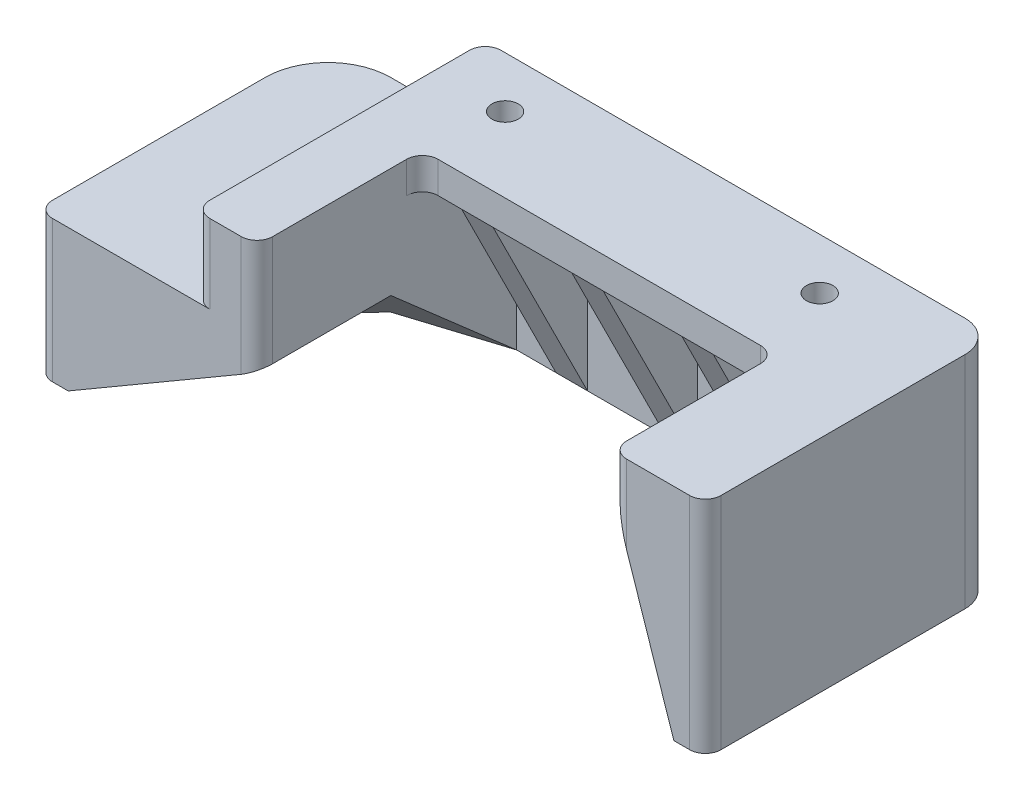
from build123d import *

# Parameters (mm, degrees)
SKETCH2_R           = 2.667
BOSS_EXTRUDE1_DEPTH = 6.35
BOSS_EXTRUDE2_DEPTH = 38.1
CUT_EXTRUDE1_DEPTH  = 50.8
CUT_EXTRUDE2_DEPTH  = 38.1
BOSS_EXTRUDE3_DEPTH = 9.525
BOSS_EXTRUDE4_DEPTH = 6.35
BOSS_EXTRUDE5_DEPTH = 22.225
CUT_EXTRUDE4_DEPTH  = 19.05
CUT_EXTRUDE7_DEPTH  = 19.05
CUT_EXTRUDE8_DEPTH  = 6.35
CUT_EXTRUDE9_DEPTH  = 6.35


with BuildPart() as part:
    # Sketch2 → Boss-Extrude1 (new body)
    with BuildSketch(Plane(origin=(0, 0, 0), x_dir=(1, 0, 0), z_dir=(0, 1, 0))):
        with BuildLine():
            Line((-109.5375, -9.525), (-109.5375, -61.948583794))
            ThreePointArc((-109.5375, -61.948583794), (-108.60756403, -64.193647824), (-106.3625, -65.123583794))
            Line((-106.3625, -65.123583794), (-100.0125, -65.123583794))
            ThreePointArc((-100.0125, -65.123583794), (-97.76743597, -64.193647824), (-96.8375, -61.948583794))
            Line((-96.8375, -61.948583794), (-96.8375, -34.925))
            ThreePointArc((-96.8375, -34.925), (-95.90756403, -32.67993597), (-93.6625, -31.75))
            Line((-93.6625, -31.75), (-28.575, -31.75))
            ThreePointArc((-28.575, -31.75), (-26.32993597, -32.67993597), (-25.4, -34.925))
            Line((-25.4, -34.925), (-25.4, -61.948583794))
            ThreePointArc((-25.4, -61.948583794), (-24.47006403, -64.193647824), (-22.225, -65.123583794))
            Line((-22.225, -65.123583794), (-9.525, -65.123583794))
            ThreePointArc((-9.525, -65.123583794), (-7.27993597, -64.193647824), (-6.35, -61.948583794))
            Line((-6.35, -61.948583794), (-6.35, -12.7))
            ThreePointArc((-6.35, -12.7), (-8.209871939, -8.209871939), (-12.7, -6.35))
            Line((-12.7, -6.35), (-106.3625, -6.35))
            ThreePointArc((-106.3625, -6.35), (-108.60756403, -7.27993597), (-109.5375, -9.525))
        make_face()
        with Locations((-95.25, -16.637060646)):
            Circle(SKETCH2_R, mode=Mode.SUBTRACT)
        with Locations((-31.75, -16.637060646)):
            Circle(SKETCH2_R, mode=Mode.SUBTRACT)
    extrude(amount=-BOSS_EXTRUDE1_DEPTH)

    # Sketch3 → Boss-Extrude2 (add)
    with BuildSketch(Plane.XZ.offset(6.35)):
        with BuildLine():
            Line((-6.35, 61.948583794), (-6.35, 12.7))
            ThreePointArc((-6.35, 12.7), (-8.209871939, 8.209871939), (-12.7, 6.35))
            Line((-12.7, 6.35), (-96.8375, 6.35))
            Line((-96.8375, 6.35), (-96.8375, 12.7))
            Line((-96.8375, 12.7), (-88.9, 12.7))
            Line((-88.9, 12.7), (-88.9, 31.75))
            Line((-88.9, 31.75), (-82.55, 31.75))
            Line((-82.55, 31.75), (-82.55, 12.7))
            Line((-82.55, 12.7), (-66.675, 12.7))
            Line((-66.675, 12.7), (-66.675, 31.75))
            Line((-66.675, 31.75), (-60.325, 31.75))
            Line((-60.325, 31.75), (-60.325, 12.7))
            Line((-60.325, 12.7), (-44.45, 12.7))
            Line((-44.45, 12.7), (-44.45, 31.75))
            Line((-44.45, 31.75), (-38.1, 31.75))
            Line((-38.1, 31.75), (-38.1, 12.7))
            Line((-38.1, 12.7), (-15.875, 12.7))
            ThreePointArc((-15.875, 12.7), (-13.62993597, 13.62993597), (-12.7, 15.875))
            Line((-12.7, 15.875), (-12.7, 27.023583794))
            Line((-12.7, 27.023583794), (-25.4, 27.023583794))
            Line((-25.4, 27.023583794), (-25.4, 33.373583794))
            Line((-25.4, 33.373583794), (-12.7, 33.373583794))
            Line((-12.7, 33.373583794), (-12.7, 42.898583794))
            Line((-12.7, 42.898583794), (-25.4, 42.898583794))
            Line((-25.4, 42.898583794), (-25.4, 49.248583794))
            Line((-25.4, 49.248583794), (-12.7, 49.248583794))
            Line((-12.7, 49.248583794), (-12.7, 58.773583794))
            Line((-12.7, 58.773583794), (-25.4, 58.773583794))
            Line((-25.4, 58.773583794), (-25.4, 61.948583794))
            ThreePointArc((-25.4, 61.948583794), (-24.47006403, 64.193647824), (-22.225, 65.123583794))
            Line((-22.225, 65.123583794), (-9.525, 65.123583794))
            ThreePointArc((-9.525, 65.123583794), (-7.27993597, 64.193647824), (-6.35, 61.948583794))
        make_face()
    extrude(amount=BOSS_EXTRUDE2_DEPTH)

    # Sketch4 → Cut-Extrude1 (cut)
    with BuildSketch(Plane.ZY.offset(88.9)):
        Polygon((31.75, -6.35), (12.7, -44.45), (31.75, -44.45), align=None)
    extrude(amount=-CUT_EXTRUDE1_DEPTH, mode=Mode.SUBTRACT)

    # Sketch5 → Cut-Extrude2 (cut)
    with BuildSketch(Plane.XY.offset(65.123583794)):
        Polygon((-25.4, -6.35), (-12.7, -44.45), (-25.4, -44.45), align=None)
    extrude(amount=-CUT_EXTRUDE2_DEPTH, mode=Mode.SUBTRACT)

    # Sketch6 → Boss-Extrude3 (add)
    with BuildSketch(Plane.XZ.offset(6.35)):
        with BuildLine():
            Line((-96.8375, 6.35), (-106.3625, 6.35))
            ThreePointArc((-106.3625, 6.35), (-108.60756403, 7.27993597), (-109.5375, 9.525))
            Line((-109.5375, 9.525), (-109.5375, 61.948583794))
            ThreePointArc((-109.5375, 61.948583794), (-108.60756403, 64.193647824), (-106.3625, 65.123583794))
            Line((-106.3625, 65.123583794), (-100.0125, 65.123583794))
            ThreePointArc((-100.0125, 65.123583794), (-97.76743597, 64.193647824), (-96.8375, 61.948583794))
            Line((-96.8375, 61.948583794), (-96.8375, 6.35))
        make_face()
    extrude(amount=BOSS_EXTRUDE3_DEPTH)

    # Sketch7 → Boss-Extrude4 (add)
    with BuildSketch(Plane.XZ.offset(15.875)):
        with BuildLine():
            Line((-100.0125, 65.123583794), (-138.1125, 65.123583794))
            ThreePointArc((-138.1125, 65.123583794), (-140.35756403, 64.193647824), (-141.2875, 61.948583794))
            Line((-141.2875, 61.948583794), (-141.2875, 19.05))
            ThreePointArc((-141.2875, 19.05), (-137.567756121, 10.069743879), (-128.5875, 6.35))
            Line((-128.5875, 6.35), (-96.8375, 6.35))
            Line((-96.8375, 6.35), (-96.8375, 61.948583794))
            ThreePointArc((-96.8375, 61.948583794), (-97.76743597, 64.193647824), (-100.0125, 65.123583794))
        make_face()
    extrude(amount=BOSS_EXTRUDE4_DEPTH)

    # Sketch8 → Boss-Extrude5 (add)
    with BuildSketch(Plane.XZ.offset(22.225)):
        with BuildLine():
            Line((-128.5875, 6.35), (-96.8375, 6.35))
            Line((-96.8375, 6.35), (-96.8375, 12.7))
            Line((-96.8375, 12.7), (-96.8375, 38.1))
            Line((-96.8375, 38.1), (-134.9375, 38.1))
            Line((-134.9375, 38.1), (-134.9375, 46.073583794))
            Line((-134.9375, 46.073583794), (-96.8375, 46.073583794))
            Line((-96.8375, 46.073583794), (-96.8375, 52.423583794))
            Line((-96.8375, 52.423583794), (-134.9375, 52.423583794))
            Line((-134.9375, 52.423583794), (-134.9375, 58.773583794))
            Line((-134.9375, 58.773583794), (-96.8375, 58.773583794))
            Line((-96.8375, 58.773583794), (-96.8375, 61.948583794))
            ThreePointArc((-96.8375, 61.948583794), (-97.76743597, 64.193647824), (-100.0125, 65.123583794))
            Line((-100.0125, 65.123583794), (-138.1125, 65.123583794))
            ThreePointArc((-138.1125, 65.123583794), (-140.35756403, 64.193647824), (-141.2875, 61.948583794))
            Line((-141.2875, 61.948583794), (-141.2875, 19.05))
            ThreePointArc((-141.2875, 19.05), (-137.567756121, 10.069743879), (-128.5875, 6.35))
        make_face()
        with BuildLine():
            Line((-128.5875, 12.7), (-103.1875, 12.7))
            Line((-103.1875, 12.7), (-103.1875, 31.75))
            Line((-103.1875, 31.75), (-134.9375, 31.75))
            Line((-134.9375, 31.75), (-134.9375, 19.05))
            ThreePointArc((-134.9375, 19.05), (-133.07762806, 14.559871939), (-128.5875, 12.7))
        make_face(mode=Mode.SUBTRACT)
    extrude(amount=BOSS_EXTRUDE5_DEPTH)

    # Sketch11 → Cut-Extrude4 (cut)
    with BuildSketch(Plane.XY.offset(65.123583794)):
        Polygon((-134.9375, -44.45), (-96.8375, -22.225), (-96.8375, -44.45), align=None)
    extrude(amount=-CUT_EXTRUDE4_DEPTH, mode=Mode.SUBTRACT)

    # Sketch23 → Cut-Extrude7 (cut)
    with BuildSketch(Plane(origin=(-0.256512778, 0.439736191, -0.384769167), x_dir=(0.915651215, 0.302516036, -0.264701531), z_dir=(-0.401973696, 0.689097765, -0.602960544))):
        Polygon((-105.477921765, 19.712805797), (-105.477921765, -14.037907158), (-147.087651949, 0.597357751), align=None)
    extrude(amount=-CUT_EXTRUDE7_DEPTH, mode=Mode.SUBTRACT)

    # Sketch24 → Cut-Extrude8 (cut)
    with BuildSketch(Plane.ZY.offset(103.1875)):
        Polygon((31.75, -31.485416667), (12.7, -44.45), (16.933333333, -44.45), align=None)
    extrude(amount=-CUT_EXTRUDE8_DEPTH, mode=Mode.SUBTRACT)

    # Sketch25 → Cut-Extrude9 (cut)
    with BuildSketch(Plane(origin=(0, 0, 31.75), x_dir=(-1, 0, 0), z_dir=(0, 0, -1))):
        Polygon((103.1875, -31.485416667), (134.9375, -44.45), (125.4125, -44.45), align=None)
    extrude(amount=-CUT_EXTRUDE9_DEPTH, mode=Mode.SUBTRACT)


solid = part.part
